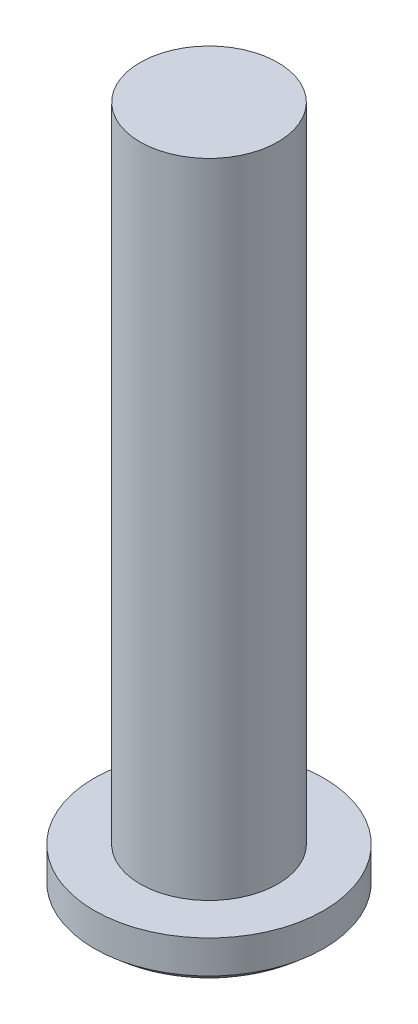
from build123d import *

# Parameters (mm, degrees)
SKETCH_1_R          = 2.5
EXTRUDE_1_DEPTH     = 1.7
SKETCH_2_R          = 1.5
EXTRUDE_2_DEPTH     = 14
CUT_EXTRUDE_1_DEPTH = 6.1


with BuildPart() as part:
    # 草图1 → 凸台-拉伸1 (new body)
    with BuildSketch(Plane(origin=(0, 0, 0), x_dir=(1, 0, 0), z_dir=(0, 1, 0))):
        Circle(SKETCH_1_R)
    extrude(amount=EXTRUDE_1_DEPTH)

    # 草图2 → 凸台-拉伸2 (add)
    with BuildSketch(Plane(origin=(0, 1.7, 0), x_dir=(1, 0, 0), z_dir=(0, 1, 0))):
        Circle(SKETCH_2_R)
    extrude(amount=EXTRUDE_2_DEPTH)

    # 草图3 one side → 切除-旋转3 (revolve, cut)
    with BuildSketch(Plane(origin=(0, 0, 0), x_dir=(0, 0, -1), z_dir=(1, 0, 0))):
        with BuildLine():
            ThreePointArc((2.5, 0.982204858), (1.343012135, 0.254359211), (0, 0))
            Line((0, 0), (0, -0.936416285))
            Line((0, -0.936416285), (3.543500435, -0.936416285))
            Line((3.543500435, -0.936416285), (2.5, 0.982204858))
        make_face()
    revolve(axis=Axis((0, 1.035939113, 0), (0, -1, 0)), mode=Mode.SUBTRACT)

    # 草图4 → 切除-拉伸1 (cut)
    with BuildSketch(Plane(origin=(0, -5, 0), x_dir=(1, 0, 0), z_dir=(0, 1, 0))):
        Polygon((-1, -0.2), (-0.2, -0.2), (-0.2, -1), (0.2, -1), (0.2, -0.2), (1, -0.2), (1, 0.2), (0.2, 0.2), (0.2, 1), (-0.2, 1), (-0.2, 0.2), (-1, 0.2), align=None)
    extrude(amount=CUT_EXTRUDE_1_DEPTH, mode=Mode.SUBTRACT)


solid = part.part
